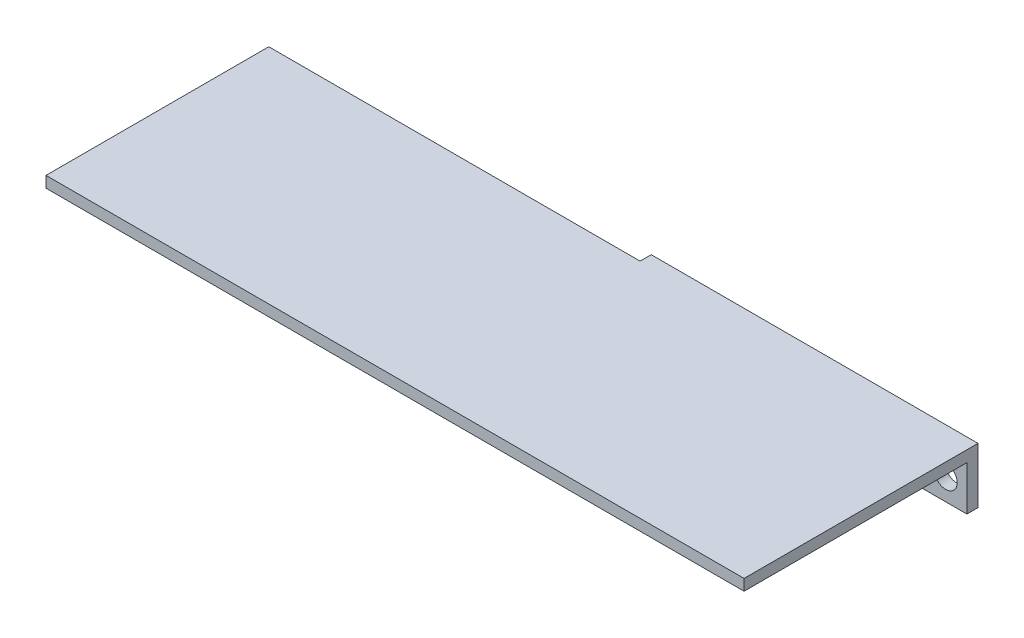
from build123d import *

# Parameters (mm, degrees)
SKETCH_1_W      = 44
SKETCH_1_H      = 6
SKETCH_1_R      = 1.55
EXTRUDE_1_DEPTH = 1.5
SKETCH_2_W      = 44
SKETCH_2_H      = 1.5
EXTRUDE_2_DEPTH = 1.5
SKETCH_4_W      = 44
SKETCH_4_H      = 1.5
EXTRUDE_4_DEPTH = 31.5
SKETCH_6_W      = 30
SKETCH_6_H      = 1.5
EXTRUDE_5_DEPTH = 50


with BuildPart() as part:
    # 草图1 → 凸台-拉伸1 (new body)
    with BuildSketch(Plane.XY):
        Rectangle(SKETCH_1_W, SKETCH_1_H)
        with Locations((-19.14418972, 0)):
            Circle(SKETCH_1_R, mode=Mode.SUBTRACT)
        with Locations((19.14418972, 0)):
            Circle(SKETCH_1_R, mode=Mode.SUBTRACT)
    extrude(amount=EXTRUDE_1_DEPTH)

    # 草图2 → 凸台-拉伸2 (add)
    with BuildSketch(Plane(origin=(0, 3, 0), x_dir=(1, 0, 0), z_dir=(0, 1, 0))):
        with Locations((0, -0.75)):
            Rectangle(SKETCH_2_W, SKETCH_2_H)
    extrude(amount=EXTRUDE_2_DEPTH)

    # 草图4 → 凸台-拉伸4 (add)
    with BuildSketch(Plane(origin=(0, 0, 0), x_dir=(-1, 0, 0), z_dir=(0, 0, -1))):
        with Locations((0, 3.75)):
            Rectangle(SKETCH_4_W, SKETCH_4_H)
    extrude(amount=-EXTRUDE_4_DEPTH)

    # 草图6 → 凸台-拉伸5 (add)
    with BuildSketch(Plane.ZY.offset(22)):
        with Locations((16.5, 3.75)):
            Rectangle(SKETCH_6_W, SKETCH_6_H)
    extrude(amount=EXTRUDE_5_DEPTH)


solid = part.part
